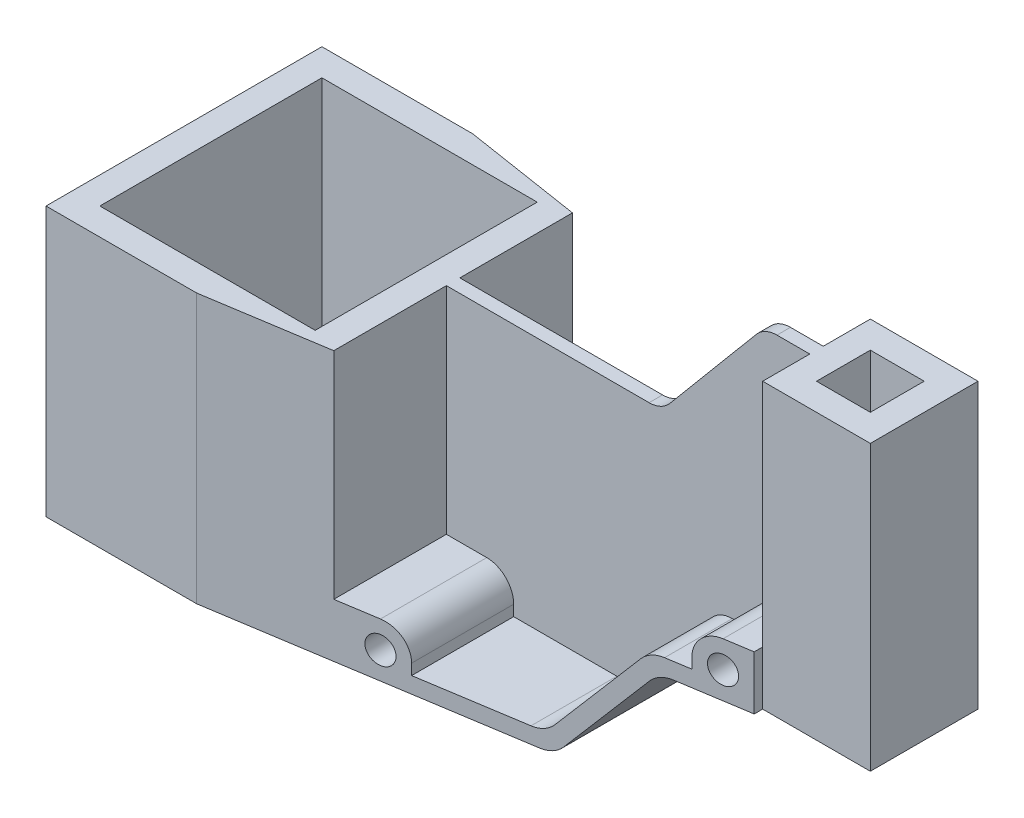
from build123d import *
from build123d.topology import SkipClean

# Parameters (mm, degrees)
BOSS_EXTRUDE1_DEPTH = 145.5
CUT_EXTRUDE1_DEPTH  = 45.5
CUT_EXTRUDE2_DEPTH  = 80
SKETCH4_W           = 80
SKETCH4_H           = 82.50000000000003
CUT_EXTRUDE3_DEPTH  = 311.05039912891584
SKETCH5_R           = 4.999999999999991
CUT_EXTRUDE4_DEPTH  = 48.75
CUT_EXTRUDE5_START  = -48.75
SKETCH6_R           = 4.9999999999999885
CUT_EXTRUDE5_DEPTH  = 48.75
SKETCH5_2_R         = 4.999999999999991
CUT_EXTRUDE6_DEPTH  = 328.569076684598
CUT_EXTRUDE7_DEPTH  = 328.569076684598
CUT_EXTRUDE8_DEPTH  = 328.569076684598
CUT_EXTRUDE9_DEPTH  = 48.75
CUT_EXTRUDE10_START = -48.75
SKETCH10_R          = 4.999999999999989
CUT_EXTRUDE10_DEPTH = 48.75
CUT_EXTRUDE11_DEPTH = 328.569076684598
SKETCH12_W          = 20.000000000000007
SKETCH12_H          = 20
CUT_EXTRUDE12_DEPTH = 328.569076684598
SKETCH13_R          = 4.999999999999989
CUT_EXTRUDE13_DEPTH = 316.7282256941878
CUT_EXTRUDE14_DEPTH = 311.05039912891584
FILLET1_R           = 10
FILLET2_R           = 10


with BuildPart() as part:
    # Sketch1 → Boss-Extrude1 (new body)
    with BuildSketch(Plane(origin=(0, 0, 0), x_dir=(1, 0, 0), z_dir=(0, 1, 0))):
        Polygon((0, 0), (-275, 0), (-275, -102.50000000000007), (0, -102.5), align=None)
    extrude(amount=BOSS_EXTRUDE1_DEPTH)

    # Sketch2 → Cut-Extrude1 (cut)
    with BuildSketch(Plane(origin=(0, 145.5, 0), x_dir=(1, 0, 0), z_dir=(0, 1, 0))):
        Polygon((-275, 0), (-107.00000000000001, 0), (-107.00000000000001, -102.50000000000007), (-275, -102.50000000000003), align=None)
    extrude(amount=-CUT_EXTRUDE1_DEPTH, mode=Mode.SUBTRACT)

    # Sketch3 → Cut-Extrude2 (cut)
    with BuildSketch(Plane(origin=(0, 99.99999999999999, 0), x_dir=(1, 0, 0), z_dir=(0, 1, 0))):
        Polygon((-107.00000000000001, 5.551e-14), (-175.00000000000003, 0), (-175.00000000000003, -48.75), (-107.00000000000001, -48.75000000000001), align=None)
        Polygon((-107.00000000000001, -102.50000000000007), (-175.00000000000003, -102.50000000000003), (-175.00000000000003, -53.75000000000002), (-107.00000000000001, -53.750000000000014), align=None)
    extrude(amount=-CUT_EXTRUDE2_DEPTH, mode=Mode.SUBTRACT)

    # Sketch4 → Cut-Extrude3 (cut, through all)
    with BuildSketch(Plane(origin=(0, 99.99999999999999, 0), x_dir=(1, 0, 0), z_dir=(0, 1, 0))):
        with Locations((-225, -51.250000000000014)):
            Rectangle(SKETCH4_W, SKETCH4_H)
    extrude(amount=-CUT_EXTRUDE3_DEPTH, mode=Mode.SUBTRACT)

    # Sketch5 → Cut-Extrude4 (cut)
    with BuildSketch(Plane.XY.offset(102.5)):
        with Locations((-160.00000000000009, 10)):
            Circle(SKETCH5_R)
        with BuildLine():
            Line((-107.00000000000007, 6.000000000000005), (-150.0000000000001, 5.999999999999997))
            Line((-150.0000000000001, 5.999999999999997), (-150.0000000000001, 10.000000000000018))
            ThreePointArc((-150.0000000000001, 10.000000000000018), (-152.92893218813464, 17.071067811865472), (-160.00000000000009, 19.99999999999999))
            Line((-160.00000000000009, 19.99999999999999), (-175.00000000000006, 19.99999999999999))
            Line((-175.00000000000006, 19.99999999999999), (-175.00000000000006, 99.99999999999999))
            Line((-175.00000000000006, 99.99999999999999), (-107.00000000000004, 99.99999999999999))
            Line((-107.00000000000004, 99.99999999999999), (-107.00000000000007, 6.000000000000005))
        make_face()
    extrude(amount=-CUT_EXTRUDE4_DEPTH, mode=Mode.SUBTRACT)

    # Sketch6 → Cut-Extrude5 (cut)
    with BuildSketch(Plane(origin=(0, 0, 0), x_dir=(-1, 0, 0), z_dir=(0, 0, -1)).offset(CUT_EXTRUDE5_START)):
        with Locations((160.00000000000006, 10.00000000000002)):
            Circle(SKETCH6_R)
        with BuildLine():
            Line((107.00000000000001, 99.99999999999999), (175.00000000000006, 99.99999999999999))
            Line((175.00000000000006, 99.99999999999999), (175.00000000000003, 19.99999999999999))
            Line((175.00000000000003, 19.99999999999999), (160.00000000000006, 19.99999999999999))
            ThreePointArc((160.00000000000006, 19.99999999999999), (152.9289321881346, 17.071067811865476), (150.00000000000009, 10.000000000000018))
            Line((150.00000000000009, 10.000000000000018), (150.00000000000009, 5.999999999999997))
            Line((150.00000000000009, 5.999999999999997), (107.00000000000004, 6.000000000000005))
            Line((107.00000000000004, 6.000000000000005), (107.00000000000001, 99.99999999999999))
        make_face()
    extrude(amount=CUT_EXTRUDE5_DEPTH, mode=Mode.SUBTRACT)

    # Sketch5_2 → Cut-Extrude6 (cut, through all)
    with SkipClean():  # the faces are left unmerged after this step: merging them gives an invalid solid
        with BuildSketch(Plane.XY.offset(102.5)):
            with Locations((-160.00000000000009, 10)):
                Circle(SKETCH5_2_R)
        extrude(amount=-CUT_EXTRUDE6_DEPTH, mode=Mode.SUBTRACT)

    # Sketch7 → Cut-Extrude7 (cut, through all)
    with SkipClean():  # the faces are left unmerged after this step: merging them gives an invalid solid
        with BuildSketch(Plane.XY.offset(102.5)):
            Polygon((-2.842e-14, 40), (-70.63816880397907, 40), (-104.20215405107005, 0), (-3.104e-14, 0), align=None)
        extrude(amount=-CUT_EXTRUDE7_DEPTH, mode=Mode.SUBTRACT)

    # Sketch8 → Cut-Extrude8 (cut, through all)
    with SkipClean():  # the faces are left unmerged after this step: merging them gives an invalid solid
        with BuildSketch(Plane.XY.offset(102.5)):
            Polygon((-107.00000000000004, 145.5), (-107.00000000000004, 99.99999999999999), (-95.02675824761518, 99.99999999999997), (-56.847725029049194, 145.5), align=None)
        extrude(amount=-CUT_EXTRUDE8_DEPTH, mode=Mode.SUBTRACT)

    # Sketch9 → Cut-Extrude9 (cut)
    with SkipClean():  # the faces are left unmerged after this step: merging them gives an invalid solid
        with BuildSketch(Plane.XY.offset(102.5)):
            with BuildLine():
                Line((-40.000000000000036, 145.5), (-40.00000000000002, 60))
                Line((-40.00000000000002, 60), (-50.00000000000003, 60))
                ThreePointArc((-50.00000000000003, 60), (-57.07106781186553, 57.071067811865454), (-60.000000000000036, 49.99999999999993))
                Line((-60.000000000000036, 49.99999999999993), (-60.000000000000036, 46))
                Line((-60.000000000000036, 46), (-73.43601475290903, 46))
                Line((-73.43601475290903, 46), (-107.00000000000007, 6.000000000000005))
                Line((-107.00000000000007, 6.000000000000005), (-107.00000000000004, 99.99999999999999))
                Line((-107.00000000000004, 99.99999999999999), (-95.02675824761518, 99.99999999999997))
                Line((-95.02675824761518, 99.99999999999997), (-56.847725029049194, 145.5))
                Line((-56.847725029049194, 145.5), (-40.000000000000036, 145.5))
            make_face()
        extrude(amount=-CUT_EXTRUDE9_DEPTH, mode=Mode.SUBTRACT)

    # Sketch10 → Cut-Extrude10 (cut)
    with SkipClean():  # the faces are left unmerged after this step: merging them gives an invalid solid
        with BuildSketch(Plane(origin=(0, 0, 0), x_dir=(-1, 0, 0), z_dir=(0, 0, -1)).offset(CUT_EXTRUDE10_START)):
            with Locations((50, 49.999999999999986)):
                Circle(SKETCH10_R)
            with BuildLine():
                Line((40.00000000000001, 145.5), (39.99999999999999, 60))
                Line((39.99999999999999, 60), (50, 60))
                ThreePointArc((50, 60), (57.071067811865504, 57.07106781186545), (60.00000000000001, 49.99999999999993))
                Line((60.00000000000001, 49.99999999999993), (60.00000000000001, 46))
                Line((60.00000000000001, 46), (73.436014752909, 46))
                Line((73.436014752909, 46), (107.00000000000004, 6.000000000000005))
                Line((107.00000000000004, 6.000000000000005), (107.00000000000001, 99.99999999999999))
                Line((107.00000000000001, 99.99999999999999), (95.02675824761515, 99.99999999999997))
                Line((95.02675824761515, 99.99999999999997), (56.847725029049165, 145.5))
                Line((56.847725029049165, 145.5), (40.00000000000001, 145.5))
            make_face()
        extrude(amount=CUT_EXTRUDE10_DEPTH, mode=Mode.SUBTRACT)

    # Sketch11 → Cut-Extrude11 (cut, through all)
    with SkipClean():  # the faces are left unmerged after this step: merging them gives an invalid solid
        with BuildSketch(Plane(origin=(0, 145.5, 0), x_dir=(1, 0, 0), z_dir=(0, 1, 0))):
            Polygon((-40.00000000000001, -71.25), (0, -71.25), (0, -102.5), (-39.99999999999999, -102.5), align=None)
            Polygon((-40.00000000000001, -31.249999999999993), (3.47e-15, -31.25), (0, 0), (-40.00000000000001, 0), align=None)
        extrude(amount=-CUT_EXTRUDE11_DEPTH, mode=Mode.SUBTRACT)

    # Sketch12 → Cut-Extrude12 (cut, through all)
    with SkipClean():  # the faces are left unmerged after this step: merging them gives an invalid solid
        with BuildSketch(Plane(origin=(0, 145.5, 0), x_dir=(1, 0, 0), z_dir=(0, 1, 0))):
            with Locations((-20, -51.24999999999999)):
                Rectangle(SKETCH12_W, SKETCH12_H)
        extrude(amount=-CUT_EXTRUDE12_DEPTH, mode=Mode.SUBTRACT)

    # Sketch13 → Cut-Extrude13 (cut, through all)
    with BuildSketch(Plane(origin=(0, 0, 48.75), x_dir=(-1, 0, 0), z_dir=(0, 0, -1))):
        with Locations((50, 49.999999999999986)):
            Circle(SKETCH13_R)
    extrude(amount=-CUT_EXTRUDE13_DEPTH, mode=Mode.SUBTRACT)

    # Sketch14 → Cut-Extrude14 (cut, through all)
    with SkipClean():  # the faces are left unmerged after this step: merging them gives an invalid solid
        with BuildSketch(Plane(origin=(0, 99.99999999999999, 0), x_dir=(1, 0, 0), z_dir=(0, 1, 0))):
            Polygon((-219.00000000000003, -8.08e-15), (-20.000000000000004, -31.249999999999996), (-20.000000000000004, 0), align=None)
            Polygon((-219.00000000000003, -102.50000000000003), (-20.000000000000004, -71.25), (-20.000000000000004, -102.50000000000003), align=None)
        extrude(amount=-CUT_EXTRUDE14_DEPTH, mode=Mode.SUBTRACT)

    # Fillet1
    fillet1_edges = [part.edges().sort_by_distance(p)[0] for p in [
        (-56.847725029049165, 145.5, 51.25),
        (-95.02675824761515, 99.99999999999997, 51.25),
        (-107.00000000000004, 6.000000000000005, 33.168969849246224),
        (-73.436014752909, 46, 35.80433301249144),
        (-107.00000000000004, 6.000000000000005, 69.33103015075378),
        (-73.436014752909, 46, 66.69566698750856),
    ]]
    fillet(fillet1_edges, radius=FILLET1_R)

    # Fillet2
    fillet2_edges = [part.edges().sort_by_distance(p)[0] for p in [
        (-70.63816880397904, 40, 51.25),
        (-104.20215405107002, -2e-17, 51.25000000000001),
    ]]
    fillet(fillet2_edges, radius=FILLET2_R)


solid = part.part
